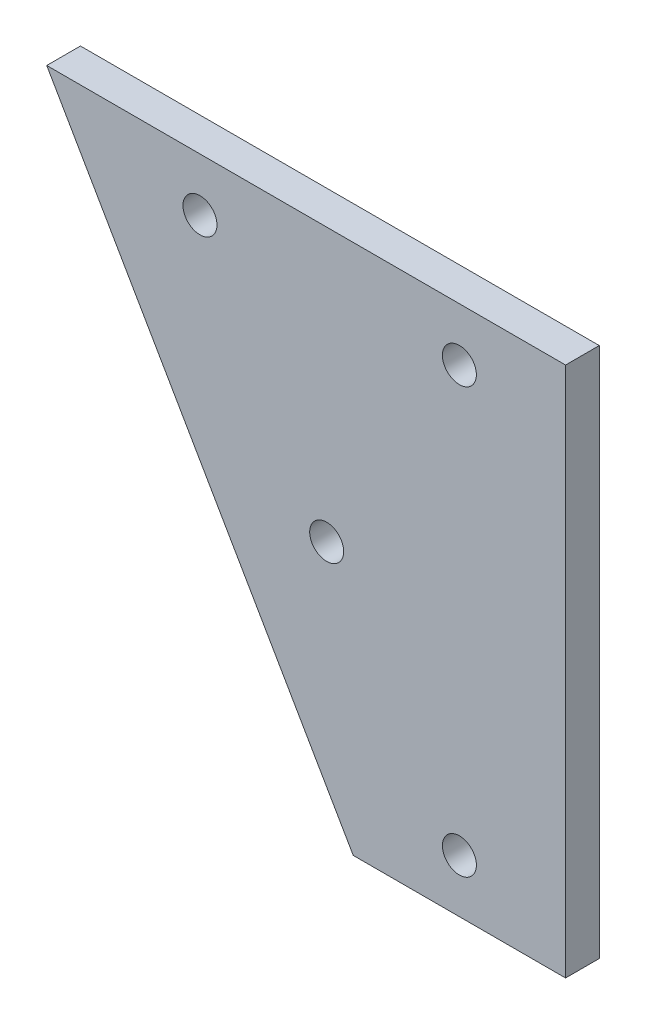
from build123d import *

# Parameters (mm, degrees)
SKETCH1_R           = 1.6
BOSS_EXTRUDE1_DEPTH = 3.175


with BuildPart() as part:
    # Sketch1 → Boss-Extrude1 (new body)
    with BuildSketch(Plane.XY):
        Polygon((0, 0), (48.867513459, 0), (48.867513459, -50), (28.867513459, -50), align=None)
        with Locations((38.867513459, -5)):
            Circle(SKETCH1_R, mode=Mode.SUBTRACT)
        with Locations((38.867513459, -45)):
            Circle(SKETCH1_R, mode=Mode.SUBTRACT)
        with Locations((14.43375673, -5)):
            Circle(SKETCH1_R, mode=Mode.SUBTRACT)
        with Locations((26.367513459, -25.669872981)):
            Circle(SKETCH1_R, mode=Mode.SUBTRACT)
    extrude(amount=BOSS_EXTRUDE1_DEPTH)


solid = part.part
